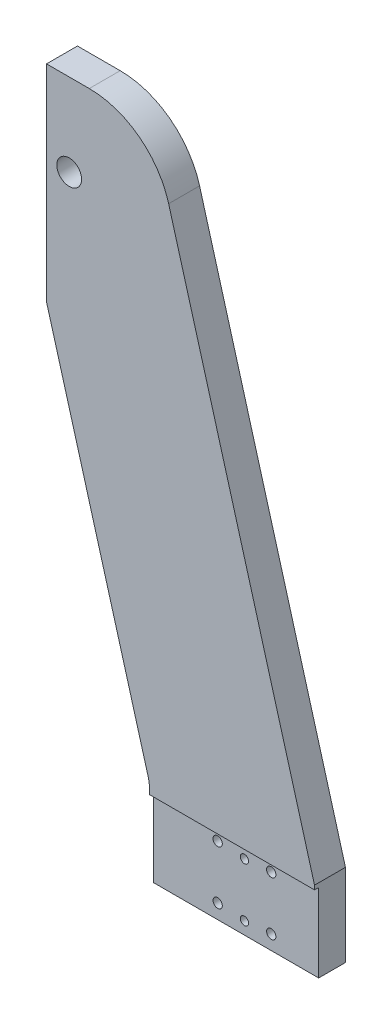
from build123d import *

# Parameters (mm, degrees)
SALIENTE_EXTRUIR1_DEPTH                              = 15
CROQUIS2_R                                           = 6
CORTAR_EXTRUIR1_DEPTH                                = 16
PERFORADOR_PARA_ROSCAR_PARA_MACHO_DE_ROS_D           = 3.3
PERFORADOR_PARA_ROSCAR_PARA_MACHO_DE_ROS_DEPTH       = 7
PERFORADOR_PARA_ROSCAR_PARA_MACHO_DE_ROS_TIP         = 0.991420021
CROQUIS9_W                                           = 80
CROQUIS9_H                                           = 38
CORTAR_EXTRUIR2_DEPTH                                = 2
TALADROS_DE_ESPIGA_DE_4_0MM1_D                       = 4
TALADROS_DE_ESPIGA_DE_4_0MM1_DEPTH                   = 17
TALADROS_DE_ESPIGA_DE_4_0MM1_TIP                     = 1.201721238
TALADRO_ROSCADO_M41_D                                = 3.3
TALADRO_ROSCADO_M41_DEPTH                            = 11.5
TALADRO_ROSCADO_M41_TIP                              = 0.991420021
REFRENTADO_PARA_TORNILLO_CON_CABEZA_HUEC_D           = 4.5
REFRENTADO_PARA_TORNILLO_CON_CABEZA_HUEC_CBORE_D     = 8
REFRENTADO_PARA_TORNILLO_CON_CABEZA_HUEC_CBORE_DEPTH = 4.4
TALADROS_DE_ESPIGA_DE_4_0MM2_D                       = 4


with BuildPart() as part:
    # Croquis1 → Saliente-Extruir1 (new body)
    with BuildSketch(Plane.XY):
        with BuildLine():
            Line((80, 0), (80, 40))
            Line((80, 40), (9.228509485, 290.860669242))
            ThreePointArc((9.228509485, 290.860669242), (-5.12786552, 311.893782856), (-29.268839302, 320))
            Line((-29.268839302, 320), (-50, 320))
            Line((-50, 320), (-50, 220))
            Line((-50, 220), (-0.751325607, 45.430334621))
            ThreePointArc((-0.751325607, 45.430334621), (-0.1887218, 42.741031935), (0, 40))
            Line((0, 40), (0, 0))
            Line((0, 0), (80, 0))
        make_face()
    extrude(amount=SALIENTE_EXTRUIR1_DEPTH)

    # Croquis2 → Cortar-Extruir1 (cut, through all)
    with BuildSketch(Plane(origin=(0, 0, 0), x_dir=(-1, 0, 0), z_dir=(0, 0, -1))):
        with Locations((39, 280)):
            Circle(CROQUIS2_R)
    extrude(amount=-CORTAR_EXTRUIR1_DEPTH, mode=Mode.SUBTRACT)

    # Perforador para roscar para macho de roscar para M44
    with Locations(Plane(origin=(0, 0, 0), x_dir=(-1, 0, 0), z_dir=(0, 0, -1))):
        with Locations((39, 261.75), (39, 298.25)):
            Hole(PERFORADOR_PARA_ROSCAR_PARA_MACHO_DE_ROS_D / 2, depth=PERFORADOR_PARA_ROSCAR_PARA_MACHO_DE_ROS_DEPTH)
            with Locations((0, 0, -(PERFORADOR_PARA_ROSCAR_PARA_MACHO_DE_ROS_DEPTH + PERFORADOR_PARA_ROSCAR_PARA_MACHO_DE_ROS_TIP / 2))):  # 118° drill point
                Cone(0, PERFORADOR_PARA_ROSCAR_PARA_MACHO_DE_ROS_D / 2, PERFORADOR_PARA_ROSCAR_PARA_MACHO_DE_ROS_TIP, mode=Mode.SUBTRACT)

    # Croquis9 → Cortar-Extruir2 (cut)
    with BuildSketch(Plane.XY.offset(15)):
        with Locations((40, 19)):
            Rectangle(CROQUIS9_W, CROQUIS9_H)
    extrude(amount=-CORTAR_EXTRUIR2_DEPTH, mode=Mode.SUBTRACT)

    # Taladros de espiga de Ø4.0mm1
    with Locations(Plane.ZY.offset(50)):
        with Locations((6, 304), (6, 256)):
            Hole(TALADROS_DE_ESPIGA_DE_4_0MM1_D / 2, depth=TALADROS_DE_ESPIGA_DE_4_0MM1_DEPTH)
            with Locations((0, 0, -(TALADROS_DE_ESPIGA_DE_4_0MM1_DEPTH + TALADROS_DE_ESPIGA_DE_4_0MM1_TIP / 2))):  # 118° drill point
                Cone(0, TALADROS_DE_ESPIGA_DE_4_0MM1_D / 2, TALADROS_DE_ESPIGA_DE_4_0MM1_TIP, mode=Mode.SUBTRACT)

    # Taladro roscado M41
    with Locations(Plane.ZY.offset(50)):
        with Locations((6, 312), (6, 248), (6, 291), (6, 269)):
            Hole(TALADRO_ROSCADO_M41_D / 2, depth=TALADRO_ROSCADO_M41_DEPTH)
            with Locations((0, 0, -(TALADRO_ROSCADO_M41_DEPTH + TALADRO_ROSCADO_M41_TIP / 2))):  # 118° drill point
                Cone(0, TALADRO_ROSCADO_M41_D / 2, TALADRO_ROSCADO_M41_TIP, mode=Mode.SUBTRACT)

    # Refrentado para tornillo con cabeza hueca de M41 (through all)
    with Locations(Plane(origin=(0, 0, 0), x_dir=(-1, 0, 0), z_dir=(0, 0, -1))):
        with Locations((-57, 7), (-57, 33), (-31, 33), (-31, 7)):
            CounterBoreHole(REFRENTADO_PARA_TORNILLO_CON_CABEZA_HUEC_D / 2, REFRENTADO_PARA_TORNILLO_CON_CABEZA_HUEC_CBORE_D / 2, REFRENTADO_PARA_TORNILLO_CON_CABEZA_HUEC_CBORE_DEPTH)

    # Taladros de espiga de Ø4.0mm2 (through all)
    with Locations(Plane(origin=(0, 0, 0), x_dir=(-1, 0, 0), z_dir=(0, 0, -1))):
        with Locations((-44, 32), (-44, 6)):
            Hole(TALADROS_DE_ESPIGA_DE_4_0MM2_D / 2)


solid = part.part
